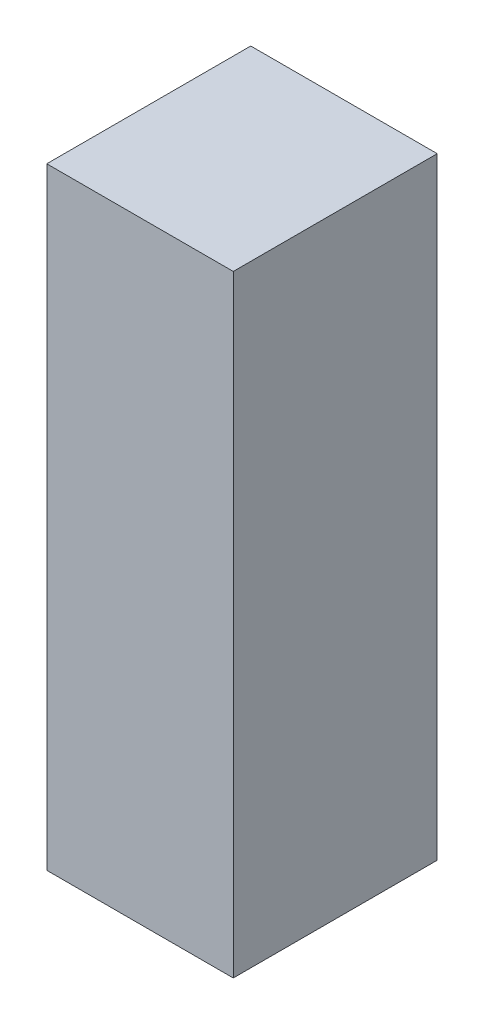
from build123d import *

# Parameters (mm, degrees)
SKETCH1_W           = 32
SKETCH1_H           = 35
BOSS_EXTRUDE1_DEPTH = 105


with BuildPart() as part:
    # Sketch1 → Boss-Extrude1 (new body)
    with BuildSketch(Plane(origin=(0, 0, 0), x_dir=(1, 0, 0), z_dir=(0, 1, 0))):
        with Locations((16, 17.5)):
            Rectangle(SKETCH1_W, SKETCH1_H)
    extrude(amount=BOSS_EXTRUDE1_DEPTH)


solid = part.part
